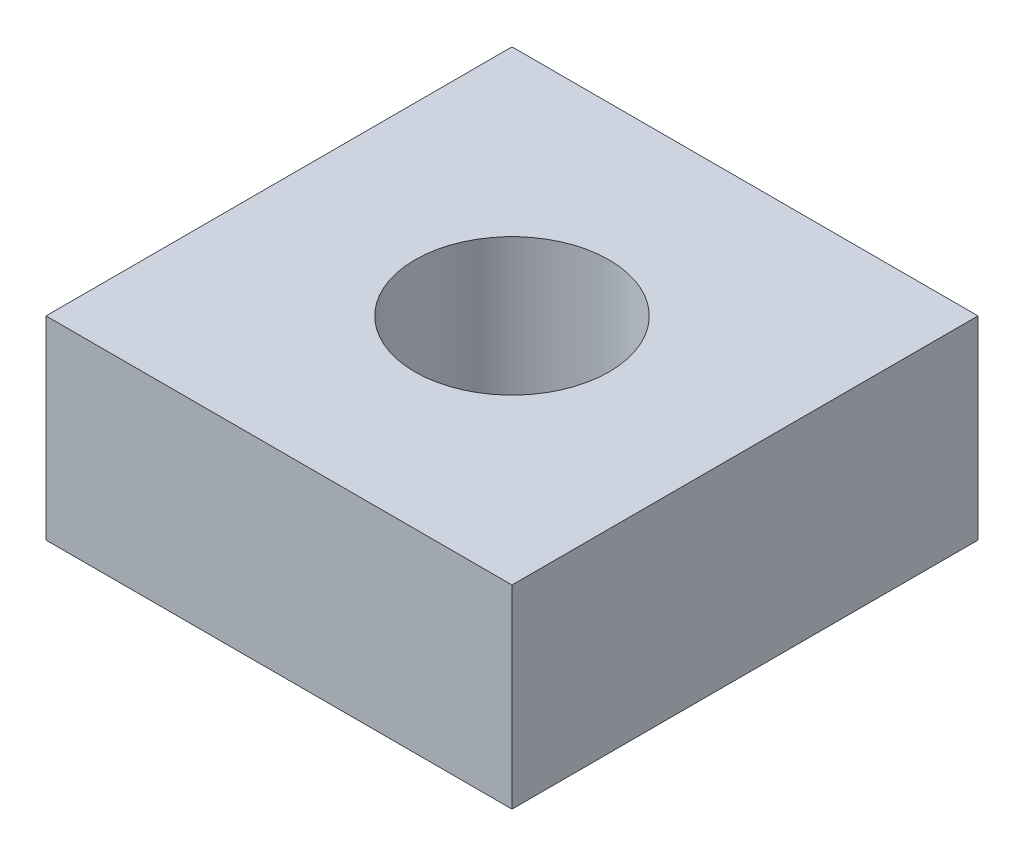
from build123d import *

# Parameters (mm, degrees)
SKETCH2_W           = 120
SKETCH2_H           = 120
BOSS_EXTRUDE1_DEPTH = 50
SKETCH3_R           = 25
CUT_EXTRUDE2_DEPTH  = 51


with BuildPart() as part:
    # Sketch2 → Boss-Extrude1 (new body)
    with BuildSketch(Plane(origin=(0, 0, 0), x_dir=(1, 0, 0), z_dir=(0, 1, 0))):
        Rectangle(SKETCH2_W, SKETCH2_H)
    extrude(amount=BOSS_EXTRUDE1_DEPTH)

    # Sketch3 → Cut-Extrude2 (cut, through all)
    with BuildSketch(Plane(origin=(0, 50, 0), x_dir=(1, 0, 0), z_dir=(0, 1, 0))):
        Circle(SKETCH3_R)
    extrude(amount=-CUT_EXTRUDE2_DEPTH, mode=Mode.SUBTRACT)


solid = part.part
